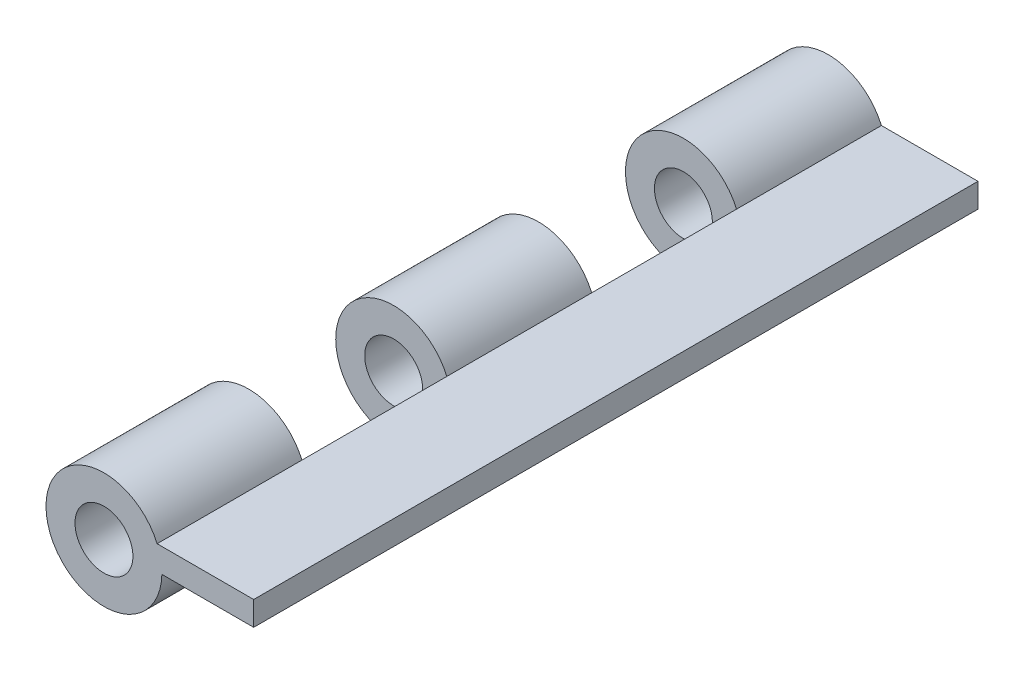
from build123d import *

# Parameters (mm, degrees)
SKETCH1_W           = 20
SKETCH1_H           = 150
BOSS_EXTRUDE1_DEPTH = 2.5
SKETCH5_R           = 12
SKETCH5_R_2         = 6
BOSS_EXTRUDE2_DEPTH = 30
LPATTERN1_COUNT     = 3
LPATTERN1_PITCH     = 60


with BuildPart() as part:
    # Sketch1 → Boss-Extrude1 (new body, symmetric)
    with BuildSketch(Plane(origin=(0, 0, 0), x_dir=(1, 0, 0), z_dir=(0, 1, 0))):
        Rectangle(SKETCH1_W, SKETCH1_H)
    extrude(amount=BOSS_EXTRUDE1_DEPTH, both=True)

    # Sketch5 → Boss-Extrude2 (add)
    with BuildSketch(Plane.XY.offset(75)):
        with Locations((-21.009649651, -2.273637457)):
            Circle(SKETCH5_R)
        with Locations((-21.009649651, -2.273637457)):
            Circle(SKETCH5_R_2, mode=Mode.SUBTRACT)
    boss_extrude2 = extrude(amount=-BOSS_EXTRUDE2_DEPTH)

    # LPattern1: Boss-Extrude2 ×3
    with Locations(*[(0, 0, -i * LPATTERN1_PITCH) for i in range(1, LPATTERN1_COUNT)]):
        add(boss_extrude2)


solid = part.part
